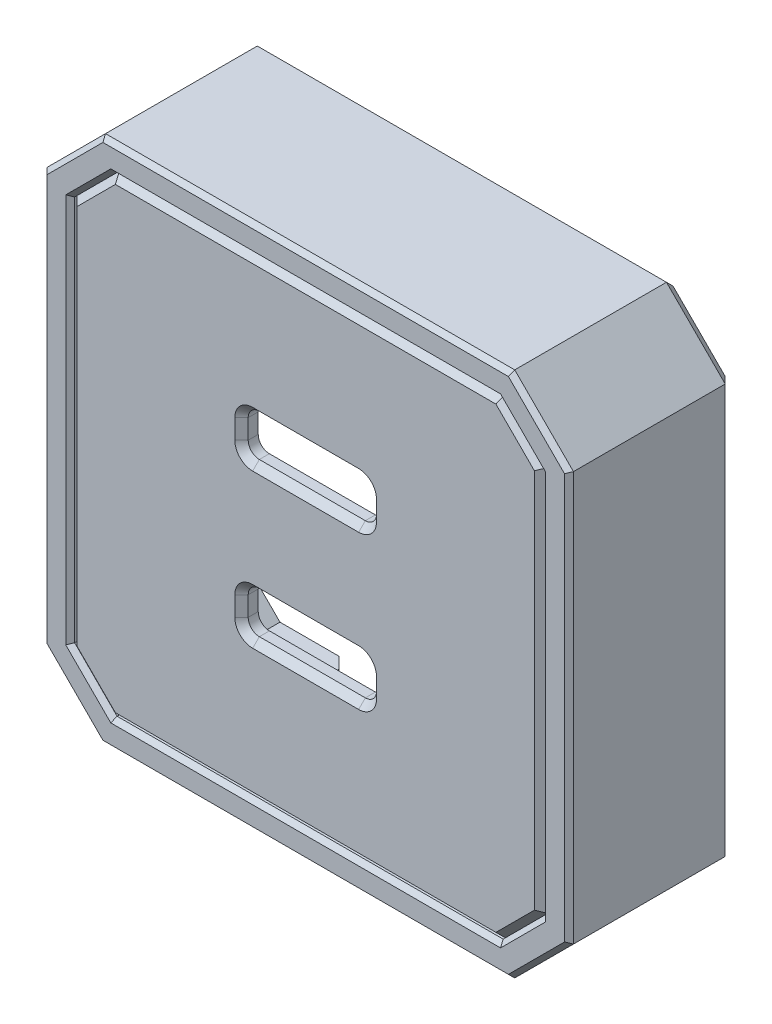
from build123d import *

# Parameters (mm, degrees)
SKETCH1_W                = 42.2
SKETCH1_H                = 42.2
SKETCH1_W_2              = 23.5
SKETCH1_H_2              = 23.5
BOSS_EXTRUDE1_DEPTH      = 5
SKETCH3_W                = 11.5
SKETCH3_H                = 3
BOSS_EXTRUDE3_DEPTH      = 1.5
CHAMFER1_SIZE            = 3.8
FILLET1_R                = 3
FILLET2_R                = 1
CHAMFER3_SIZE            = 0.5
CHAMFER4_SIZE            = 0.6
BOSS_EXTRUDE5_DEPTH      = 5
BOSS_EXTRUDE5_DEPTH_BACK = 10
CHAMFER5_SIZE            = 0.4
CUT_EXTRUDE4_START       = -10
SKETCH8_W                = 22
SKETCH8_H                = 2.5
CUT_EXTRUDE4_DEPTH       = 10
CHAMFER6_SIZE            = 1


with BuildPart() as part:
    # Sketch1 → Boss-Extrude1 (new body)
    with BuildSketch(Plane.XY):
        Rectangle(SKETCH1_W, SKETCH1_H)
        Rectangle(SKETCH1_W_2, SKETCH1_H_2, mode=Mode.SUBTRACT)
    extrude(amount=BOSS_EXTRUDE1_DEPTH)

    # Sketch3 → Boss-Extrude3 (add)
    with BuildSketch(Plane.XY.offset(5)):
        Polygon((11.75, 11.75), (5.75, 11.75), (5.75, 8.75), (5.75, 5), (-5.75, 5), (-5.75, 8.75), (-5.75, 11.75), (-11.75, 11.75), (-11.75, -11.75), (-5.75, -11.75), (-5.75, -8.75), (-5.75, -5), (5.75, -5), (5.75, -8.75), (5.75, -11.75), (11.75, -11.75), align=None)
        with Locations((0, 10.25)):
            Rectangle(SKETCH3_W, SKETCH3_H)
        with Locations((0, -10.25)):
            Rectangle(SKETCH3_W, SKETCH3_H)
    extrude(amount=-BOSS_EXTRUDE3_DEPTH)

    # Chamfer1
    chamfer1_edges = [part.edges().sort_by_distance(p)[0] for p in [
        (21.1, -21.1, 2.5),
        (-21.1, -21.1, 2.5),
        (-21.1, 21.1, 2.5),
        (21.1, 21.1, 2.5),
    ]]
    chamfer(chamfer1_edges, length=CHAMFER1_SIZE)

    # Fillet1
    fillet1_edges = [part.edges().sort_by_distance(p)[0] for p in [
        (-11.75, -11.75, 1.75),
        (11.75, -11.75, 1.75),
        (-11.75, 11.75, 1.75),
        (11.75, 11.75, 1.75),
    ]]
    fillet(fillet1_edges, radius=FILLET1_R)

    # Fillet2
    fillet2_edges = [part.edges().sort_by_distance(p)[0] for p in [
        (5.75, 8.75, 4.25),
        (-5.75, 8.75, 4.25),
        (-5.75, 5, 4.25),
        (5.75, -8.75, 4.25),
        (5.75, -5, 4.25),
        (-5.75, -5, 4.25),
        (5.75, 5, 4.25),
        (-5.75, -8.75, 4.25),
    ]]
    fillet(fillet2_edges, radius=FILLET2_R)

    # Chamfer3
    chamfer3_edges = [part.edges().sort_by_distance(p)[0] for p in [
        (-10.871320344, -10.871320344, 0),
        (-10.871320344, 10.871320344, 0),
        (10.871320344, -10.871320344, 0),
        (10.871320344, 10.871320344, 0),
        (-11.75, 0, 0),
        (0, -11.75, 0),
        (0, 11.75, 0),
        (11.75, 0, 0),
    ]]
    chamfer(chamfer3_edges, length=CHAMFER3_SIZE)

    # Chamfer4
    chamfer4_edges = [part.edges().sort_by_distance(p)[0] for p in [
        (0, -8.75, 5),
        (-5.75, -6.875, 5),
        (0, -5, 5),
        (5.75, -6.875, 5),
        (5.75, 6.875, 5),
        (0, 5, 5),
        (-5.75, 6.875, 5),
        (0, 8.75, 5),
        (-5.457106781, -8.457106781, 5),
        (-5.457106781, -5.292893219, 5),
        (5.457106781, -5.292893219, 5),
        (5.457106781, -8.457106781, 5),
        (5.457106781, 5.292893219, 5),
        (-5.457106781, 5.292893219, 5),
        (-5.457106781, 8.457106781, 5),
        (5.457106781, 8.457106781, 5),
        (0, 21.1, 5),
        (21.1, 0, 5),
        (-21.1, 0, 5),
        (0, -21.1, 5),
        (-19.2, -19.2, 5),
        (-19.2, 19.2, 5),
        (19.2, -19.2, 5),
        (19.2, 19.2, 5),
    ]]
    chamfer(chamfer4_edges, length=CHAMFER4_SIZE)

    # Sketch7 → Boss-Extrude5 (add, two sides)
    with BuildSketch(Plane.XY) as boss_extrude5_sk:
        Polygon((18.335533906, 23.6), (-18.335533906, 23.6), (-23.6, 18.335533906), (-23.6, -18.335533906), (-18.335533906, -23.6), (18.335533906, -23.6), (23.6, -18.335533906), (23.6, 18.335533906), align=None)
        Polygon((17.3, 21.1), (-17.3, 21.1), (-21.1, 17.3), (-21.1, -17.3), (-17.3, -21.1), (17.3, -21.1), (21.1, -17.3), (21.1, 17.3), align=None, mode=Mode.SUBTRACT)
    extrude(amount=BOSS_EXTRUDE5_DEPTH)
    extrude(boss_extrude5_sk.sketch, amount=-BOSS_EXTRUDE5_DEPTH_BACK)

    # Chamfer5
    chamfer5_edges = [part.edges().sort_by_distance(p)[0] for p in [
        (20.967766953, 20.967766953, 5),
        (0, 23.6, 5),
        (-20.967766953, 20.967766953, 5),
        (-23.6, 0, 5),
        (-20.967766953, -20.967766953, 5),
        (0, -23.6, 5),
        (20.967766953, -20.967766953, 5),
        (23.6, 0, 5),
        (-19.2, 19.2, 5),
        (-21.1, 0, 5),
        (-19.2, -19.2, 5),
        (0, -21.1, 5),
        (19.2, -19.2, 5),
        (21.1, 0, 5),
        (19.2, 19.2, 5),
        (0, 21.1, 5),
    ]]
    chamfer(chamfer5_edges, length=CHAMFER5_SIZE)

    # Sketch8 → Cut-Extrude4 (cut)
    with BuildSketch(Plane(origin=(0, 0, -10), x_dir=(-1, 0, 0), z_dir=(0, 0, -1)).offset(CUT_EXTRUDE4_START)):
        with Locations((0, -22.35)):
            Rectangle(SKETCH8_W, SKETCH8_H)
    extrude(amount=CUT_EXTRUDE4_DEPTH, mode=Mode.SUBTRACT)

    # Chamfer6
    chamfer6_edges = [part.edges().sort_by_distance(p)[0] for p in [
        (20.967766953, 20.967766953, -10),
        (0, 23.6, -10),
        (-20.967766953, 20.967766953, -10),
        (-23.6, 0, -10),
        (-20.967766953, -20.967766953, -10),
        (-14.667766953, -23.6, -10),
        (20.967766953, -20.967766953, -10),
        (23.6, 0, -10),
        (14.667766953, -23.6, -10),
        (11, -22.35, -10),
        (-11, -22.35, -10),
    ]]
    chamfer(chamfer6_edges, length=CHAMFER6_SIZE)


solid = part.part
